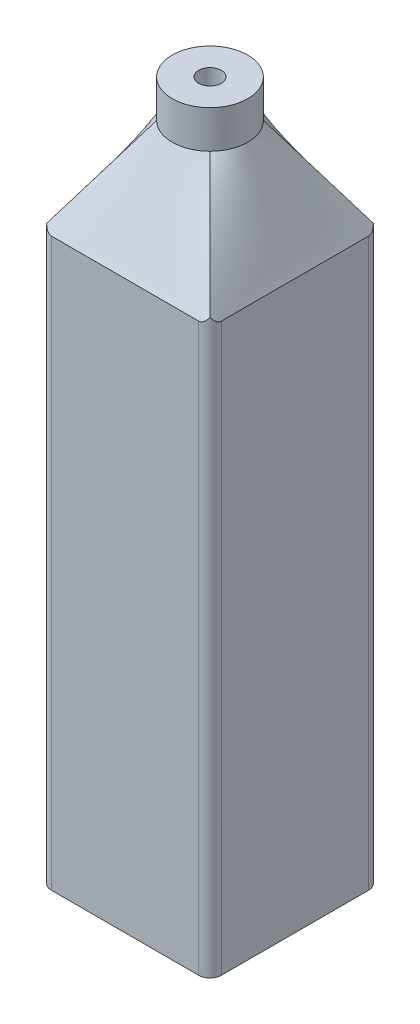
from build123d import *

# Parameters (mm, degrees)
SKETCH_1_W          = 45
SKETCH_1_H          = 45
EXTRUDE_1_DEPTH     = 150
SKETCH_2_W          = 45
SKETCH_2_H          = 45
EXTRUDE_2_DEPTH     = 10
SKETCH_5_R          = 3
CUT_EXTRUDE_1_DEPTH = 30
FILLET_1_R          = 3


with BuildPart() as part:
    # 草图1 → 凸台-拉伸1 (new body)
    with BuildSketch(Plane(origin=(0, 0, 0), x_dir=(1, 0, 0), z_dir=(0, 1, 0))):
        Rectangle(SKETCH_1_W, SKETCH_1_H)
    extrude(amount=EXTRUDE_1_DEPTH)

    # 草图3 for 放样1 → 放样1 section 0
    with BuildSketch(Plane(origin=(0, 175, 0), x_dir=(1, 0, 0), z_dir=(0, 1, 0))):
        with BuildLine():
            # circular arc as an exact rational Bezier (weights 1, cos(half-angle), 1)
            Bezier((7.071067812, -7.071067812), (14.142135623, 0), (7.071067812, 7.071067812), weights=[1, 0.707106781, 1])
            Bezier((7.071067812, 7.071067812), (0, 14.142135623), (-7.071067812, 7.071067812), weights=[1, 0.707106781, 1])
            Bezier((-7.071067812, 7.071067812), (-14.142135623, 0), (-7.071067812, -7.071067812), weights=[1, 0.707106781, 1])
            Bezier((-7.071067812, -7.071067812), (0, -14.142135623), (7.071067812, -7.071067812), weights=[1, 0.707106781, 1])
        make_face()
    # 草图2 → 放样1 section 1
    with BuildSketch(Plane(origin=(0, 150, 0), x_dir=(1, 0, 0), z_dir=(0, 1, 0))):
        Rectangle(SKETCH_2_W, SKETCH_2_H)
    loft()

    # 草图4 → 凸台-拉伸2 (add)
    with BuildSketch(Plane(origin=(0, 175, 0), x_dir=(1, 0, 0), z_dir=(0, 1, 0))):
        with BuildLine():
            ThreePointArc((-7.071067812, 7.071067812), (-10, 0), (-7.071067812, -7.071067812))
            ThreePointArc((-7.071067812, -7.071067812), (0, -10), (7.071067812, -7.071067812))
            ThreePointArc((7.071067812, -7.071067812), (10, 0), (7.071067812, 7.071067812))
            ThreePointArc((7.071067812, 7.071067812), (0, 10), (-7.071067812, 7.071067812))
        make_face()
    extrude(amount=EXTRUDE_2_DEPTH)

    # 草图5 → 切除-拉伸1 (cut)
    with BuildSketch(Plane(origin=(0, 185, 0), x_dir=(1, 0, 0), z_dir=(0, 1, 0))):
        with Locations(Location((0, 0, 0), (0, 0, 270))):
            Circle(SKETCH_5_R)
    extrude(amount=-CUT_EXTRUDE_1_DEPTH, mode=Mode.SUBTRACT)

    # 圆角1
    fillet_1_edges = [part.edges().sort_by_distance(p)[0] for p in [
        (22.5, 75, -22.5),
        (22.5, 75, 22.5),
        (-22.5, 75, -22.5),
        (-22.5, 75, 22.5),
    ]]
    fillet(fillet_1_edges, radius=FILLET_1_R)


solid = part.part
